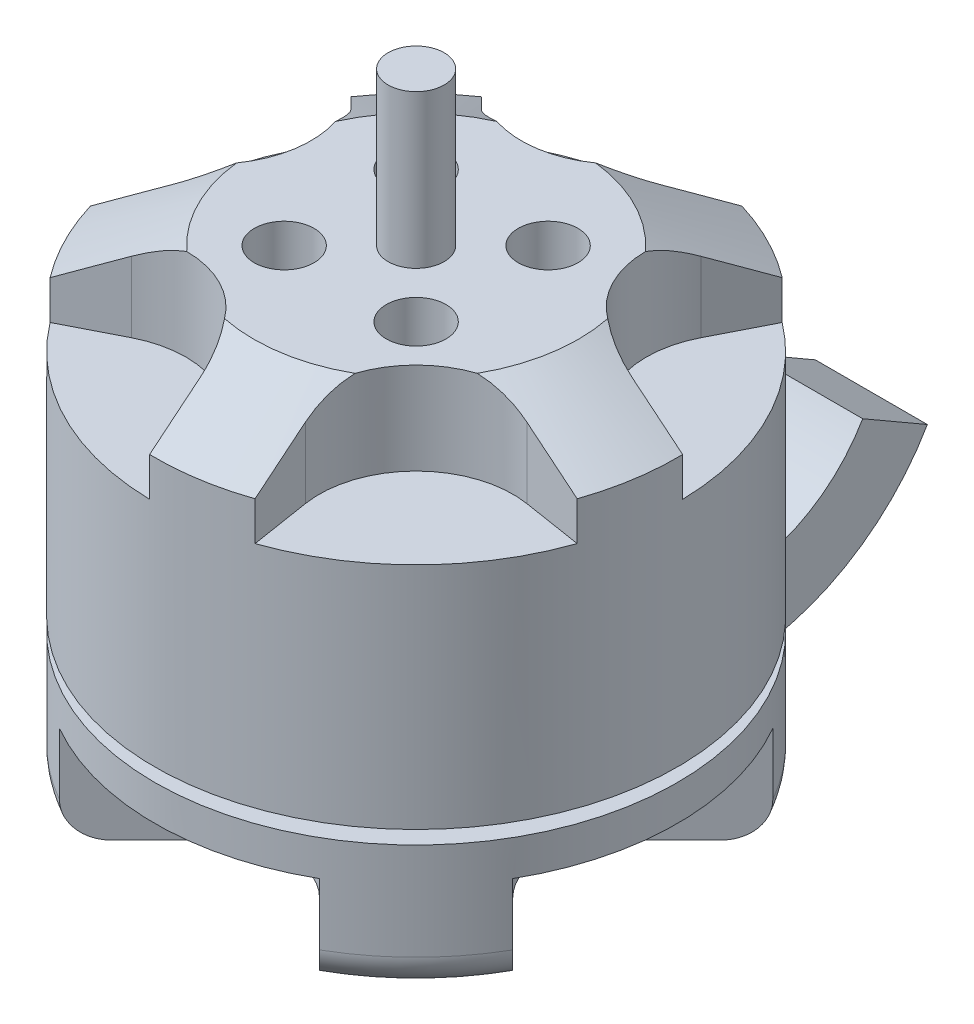
from build123d import *

# Parameters (mm, degrees)
M2X0_4_TAPPED_HOLE1_D     = 1.6
M2X0_4_TAPPED_HOLE1_DEPTH = 3.2
M2X0_4_TAPPED_HOLE1_TIP   = 0.480688495
M2X0_4_TAPPED_HOLE2_D     = 1.6
M2X0_4_TAPPED_HOLE2_DEPTH = 5.2
M2X0_4_TAPPED_HOLE2_TIP   = 0.480688495
CHAMFER1_SIZE             = 2.65
CHAMFER1_SIZE2            = 1.42
FILLET1_R                 = 0.935
CUT_EXTRUDE1_DEPTH        = 2.59
SKETCH13_W                = 9.661742765
SKETCH13_H                = 0.36
CUT_EXTRUDE2_DEPTH        = 2.46
SKETCH7_W                 = 3
SKETCH7_H                 = 2
REVOLVE3_ANGLE            = 60
REVOLVE3_OTHER_WAY_ANGLE  = 10


with BuildPart() as part:
    # Sketch1 → Revolve1 (revolve)
    with BuildSketch(Plane.XY):
        Polygon((-0.75, 0), (-7, 0), (-7, 12.5), (-0.75, 12.5), (-0.75, 16.6), (0, 16.6), (0, -0.9), (-0.75, -0.9), align=None)
    revolve(axis=Axis((0, -74.460023863, 0), (0, 1, 0)))

    # M2x0.4 Tapped Hole1
    with Locations(Plane(origin=(0, 0, 0), x_dir=(-1, 0, 0), z_dir=(0, -1, 0))):
        with Locations((3.181980515, -3.181980515), (-3.181980515, -3.181980515), (-3.181980515, 3.181980515), (3.181980515, 3.181980515)):
            Hole(M2X0_4_TAPPED_HOLE1_D / 2, depth=M2X0_4_TAPPED_HOLE1_DEPTH)
            with Locations((0, 0, -(M2X0_4_TAPPED_HOLE1_DEPTH + M2X0_4_TAPPED_HOLE1_TIP / 2))):  # 118° drill point
                Cone(0, M2X0_4_TAPPED_HOLE1_D / 2, M2X0_4_TAPPED_HOLE1_TIP, mode=Mode.SUBTRACT)

    # M2x0.4 Tapped Hole2
    with Locations(Plane(origin=(0, 12.5, 0), x_dir=(1, 0, 0), z_dir=(0, 1, 0))):
        with Locations((-1.767766953, 1.767766953), (1.767766953, 1.767766953), (1.767766953, -1.767766953), (-1.767766953, -1.767766953)):
            Hole(M2X0_4_TAPPED_HOLE2_D / 2, depth=M2X0_4_TAPPED_HOLE2_DEPTH)
            with Locations((0, 0, -(M2X0_4_TAPPED_HOLE2_DEPTH + M2X0_4_TAPPED_HOLE2_TIP / 2))):  # 118° drill point
                Cone(0, M2X0_4_TAPPED_HOLE2_D / 2, M2X0_4_TAPPED_HOLE2_TIP, mode=Mode.SUBTRACT)

    # Chamfer1
    chamfer1_edges = [part.edges().sort_by_distance(p)[0] for p in [
        (7, 12.5, 0),
    ]]
    chamfer1_side = [part.faces().sort_by_distance(p)[0] for p in [
        (6.802010101, 12.5, 0),
    ]]
    chamfer(chamfer1_edges, length=CHAMFER1_SIZE, length2=CHAMFER1_SIZE2, reference=chamfer1_side[0])

    # Fillet1
    fillet1_edges = [part.edges().sort_by_distance(p)[0] for p in [
        (7, 0, 0),
    ]]
    fillet(fillet1_edges, radius=FILLET1_R)

    # Sketch10 → Cut-Extrude1 (cut)
    with BuildSketch(Plane(origin=(0, 0, 0), x_dir=(-1, 0, 0), z_dir=(0, -1, 0))):
        with BuildLine():
            Line((1.33664614, 3.924656959), (4.411989181, 7))
            Line((4.411989181, 7), (-4.411989181, 7))
            Line((-4.411989181, 7), (-1.33664614, 3.924656959))
            ThreePointArc((-1.33664614, 3.924656959), (0, 3.371), (1.33664614, 3.924656959))
        make_face()
        with BuildLine():
            Line((3.924656959, 1.33664614), (7, 4.411989181))
            Line((7, 4.411989181), (7, -4.411989181))
            Line((7, -4.411989181), (3.924656959, -1.33664614))
            ThreePointArc((3.924656959, -1.33664614), (3.371, 0), (3.924656959, 1.33664614))
        make_face()
        with BuildLine():
            Line((1.33664614, -3.924656959), (4.411989181, -7))
            Line((4.411989181, -7), (-4.411989181, -7))
            Line((-4.411989181, -7), (-1.33664614, -3.924656959))
            ThreePointArc((-1.33664614, -3.924656959), (0, -3.371), (1.33664614, -3.924656959))
        make_face()
        with BuildLine():
            Line((-3.924656959, -1.33664614), (-7, -4.411989181))
            Line((-7, -4.411989181), (-7, 4.411989181))
            Line((-7, 4.411989181), (-3.924656959, 1.33664614))
            ThreePointArc((-3.924656959, 1.33664614), (-3.371, 0), (-3.924656959, -1.33664614))
        make_face()
    extrude(amount=-CUT_EXTRUDE1_DEPTH, mode=Mode.SUBTRACT)

    # Sketch13 → Cut-Revolve1 (revolve, cut)
    with BuildSketch(Plane.XY):
        with Locations((9.100871383, 3.72)):
            Rectangle(SKETCH13_W, SKETCH13_H)
    revolve(axis=Axis((0, 7.126821905, 0), (0, -1, 0)), mode=Mode.SUBTRACT)

    # Sketch14 → Cut-Extrude2 (cut)
    with BuildSketch(Plane(origin=(0, 12.5, -12.5), x_dir=(1, 0, 0), z_dir=(0, -1, 0))):
        with BuildLine():
            Line((5.011535009, 14.544143598), (7.466519927, 14.93297501))
            Line((7.466519927, 14.93297501), (2.43297501, 19.966519927))
            Line((2.43297501, 19.966519927), (2.044143598, 17.511535009))
            ThreePointArc((2.044143598, 17.511535009), (2.771858582, 15.271858582), (5.011535009, 14.544143598))
        make_face()
        with BuildLine():
            Line((5.397928138, 12.104553397), (7.852913055, 12.493384809))
            Line((7.852913055, 12.493384809), (4.621178283, 6.150748195))
            Line((4.621178283, 6.150748195), (3.492745575, 8.365422084))
            ThreePointArc((3.492745575, 8.365422084), (3.492745575, 10.720357241), (5.397928138, 12.104553397))
        make_face()
        with BuildLine():
            Line((1.29195946, 7.244065549), (2.420392169, 5.02939166))
            Line((2.420392169, 5.02939166), (-4.610474679, 6.142971571))
            Line((-4.610474679, 6.142971571), (-2.85289953, 7.900546721))
            ThreePointArc((-2.85289953, 7.900546721), (-0.613223103, 8.628261705), (1.29195946, 7.244065549))
        make_face()
        with BuildLine():
            Line((-4.599453279, 9.64710047), (-6.357028429, 7.889525321))
            Line((-6.357028429, 7.889525321), (-7.47060834, 14.920392169))
            Line((-7.47060834, 14.920392169), (-5.255934451, 13.79195946))
            ThreePointArc((-5.255934451, 13.79195946), (-3.871738295, 11.886776897), (-4.599453279, 9.64710047))
        make_face()
        with BuildLine():
            Line((-4.134577916, 15.992745575), (-6.349251805, 17.121178283))
            Line((-6.349251805, 17.121178283), (-0.006615191, 20.352913055))
            Line((-0.006615191, 20.352913055), (-0.395446603, 17.897928138))
            ThreePointArc((-0.395446603, 17.897928138), (-1.779642759, 15.992745575), (-4.134577916, 15.992745575))
        make_face()
    extrude(amount=CUT_EXTRUDE2_DEPTH, mode=Mode.SUBTRACT)


with BuildPart() as body_2:
    # Sketch7 → Revolve3 (revolve)
    with BuildSketch(Plane(origin=(0, 0, -7), x_dir=(-1, 0, 0), z_dir=(0, 0, -1))):
        with Locations((0, 1)):
            Rectangle(SKETCH7_W, SKETCH7_H)
    revolve(axis=Axis((-7, 6, -7), (1, 0, 0)), revolution_arc=REVOLVE3_ANGLE)

    # Sketch7 → Revolve3 other way (revolve)
    with BuildSketch(Plane(origin=(0, 0, -7), x_dir=(-1, 0, 0), z_dir=(0, 0, -1))):
        with Locations((0, 1)):
            Rectangle(SKETCH7_W, SKETCH7_H)
    revolve(axis=Axis((-7, 6, -7), (-1, 0, 0)), revolution_arc=REVOLVE3_OTHER_WAY_ANGLE)


solid = Compound([part.part, body_2.part])
